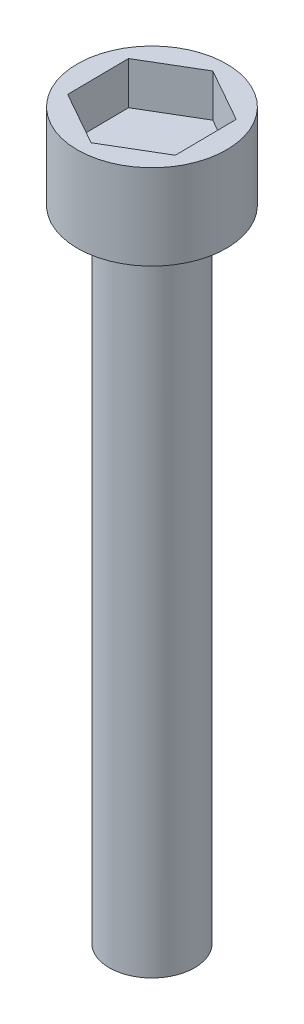
from build123d import *

# Parameters (mm, degrees)
SKETCH_1_R          = 3.5
EXTRUDE_1_DEPTH     = 4
SKETCH_2_R          = 2
EXTRUDE_2_DEPTH     = 30
CUT_EXTRUDE_1_DEPTH = 2


with BuildPart() as part:
    # 草图1 → 凸台-拉伸1 (new body)
    with BuildSketch(Plane(origin=(0, 0, 0), x_dir=(1, 0, 0), z_dir=(0, 1, 0))):
        Circle(SKETCH_1_R)
    extrude(amount=-EXTRUDE_1_DEPTH)

    # 草图2 → 凸台-拉伸2 (add)
    with BuildSketch(Plane.XZ.offset(4)):
        Circle(SKETCH_2_R)
    extrude(amount=EXTRUDE_2_DEPTH)

    # 草图3 → 切除-拉伸1 (cut)
    with BuildSketch(Plane(origin=(0, 0, 0), x_dir=(1, 0, 0), z_dir=(0, 1, 0))):
        Polygon((2.51555192, -1.416097409), (2.484152291, 1.470483162), (-0.031399629, 2.886580572), (-2.51555192, 1.416097409), (-2.484152291, -1.470483162), (0.031399629, -2.886580572), align=None)
    extrude(amount=-CUT_EXTRUDE_1_DEPTH, mode=Mode.SUBTRACT)


solid = part.part
